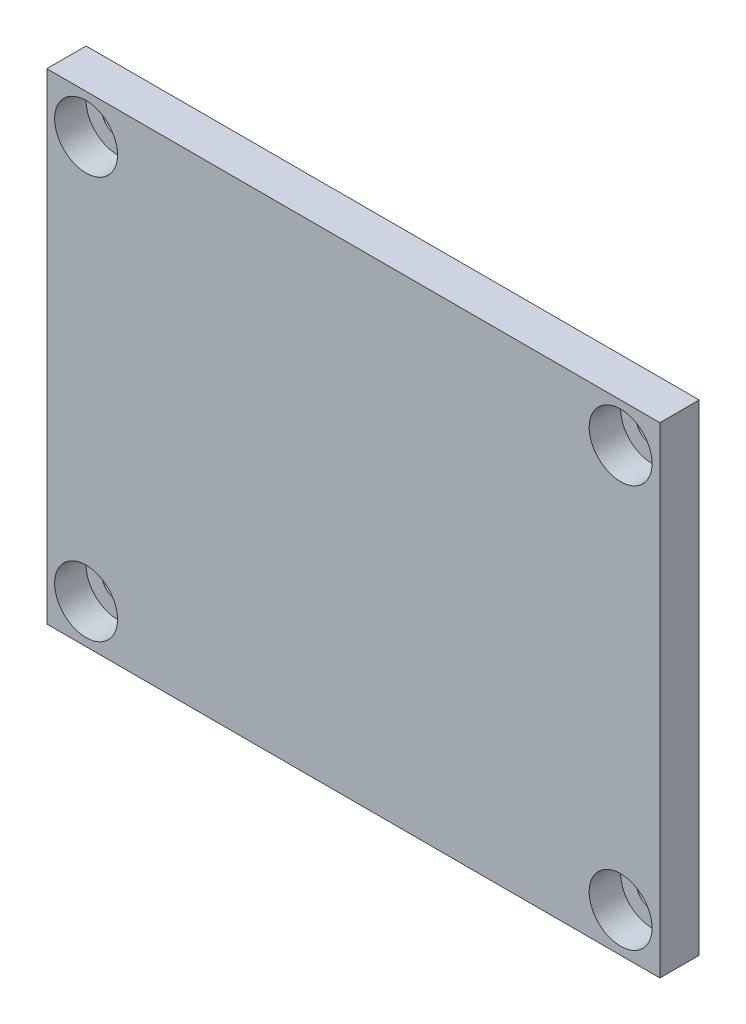
from build123d import *

# Parameters (mm, degrees)
SKETCH_1_W                   = 39
SKETCH_1_H                   = 30.59
EXTRUDE_1_DEPTH              = 2.5
SKETCH_2_W                   = 5
SKETCH_2_H                   = 5
EXTRUDE_2_DEPTH              = 2.5
HOLE_WIZARD_M2_8_D           = 2
HOLE_WIZARD_M2_8_DEPTH       = 3
HOLE_WIZARD_M2_8_CBORE_D     = 4
HOLE_WIZARD_M2_8_CBORE_DEPTH = 2
HOLE_WIZARD_M2_7_D           = 2
HOLE_WIZARD_M2_7_DEPTH       = 3
HOLE_WIZARD_M2_7_CBORE_D     = 4
HOLE_WIZARD_M2_7_CBORE_DEPTH = 2


with BuildPart() as part:
    # 草图1 → 凸台-拉伸1 (new body)
    with BuildSketch(Plane.XY):
        with Locations((19.5, 15.295)):
            Rectangle(SKETCH_1_W, SKETCH_1_H)
    extrude(amount=-EXTRUDE_1_DEPTH)

    # 草图2 → 凸台-拉伸2 (add)
    with BuildSketch(Plane.XY):
        with Locations((2.5, 2.5)):
            Rectangle(SKETCH_2_W, SKETCH_2_H)
        with Locations((36.5, 28.09)):
            Rectangle(SKETCH_2_W, SKETCH_2_H)
    extrude(amount=-EXTRUDE_2_DEPTH)

    # M2 六角头螺栓的柱形沉头孔8
    with Locations(Plane(origin=(2.5, 2.5, 0), x_dir=(1, 0, 0), z_dir=(0, 0, 1))):
        with Locations((0, 0), (34, 25.59)):
            CounterBoreHole(HOLE_WIZARD_M2_8_D / 2, HOLE_WIZARD_M2_8_CBORE_D / 2, HOLE_WIZARD_M2_8_CBORE_DEPTH, depth=HOLE_WIZARD_M2_8_DEPTH)

    # M2 六角头螺栓的柱形沉头孔7
    with Locations(Plane.XY):
        with Locations((2.5, 28.09), (36.5, 2.5)):
            CounterBoreHole(HOLE_WIZARD_M2_7_D / 2, HOLE_WIZARD_M2_7_CBORE_D / 2, HOLE_WIZARD_M2_7_CBORE_DEPTH, depth=HOLE_WIZARD_M2_7_DEPTH)


solid = part.part
